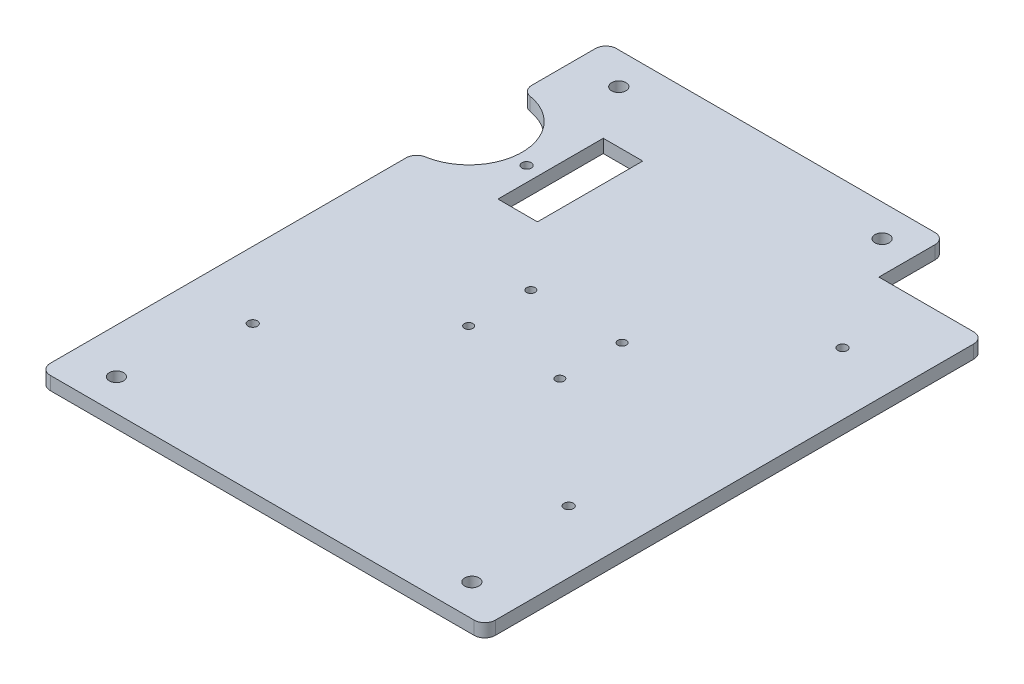
from build123d import *

# Parameters (mm, degrees)
SKETCH1_R           = 1.7272
BOSS_EXTRUDE1_DEPTH = 3.2004
SKETCH2_W           = 9.525
SKETCH2_H           = 25.4
CUT_EXTRUDE1_DEPTH  = 3.2004
SKETCH3_R           = 1.1303
CUT_EXTRUDE2_DEPTH  = 3.2004
FILLET1_R           = 2.54
SKETCH4_R           = 1.02489
CUT_EXTRUDE3_DEPTH  = 3.2004


with BuildPart() as part:
    # Sketch1 → Boss-Extrude1 (new body)
    with BuildSketch(Plane(origin=(0, 0, 0), x_dir=(1, 0, 0), z_dir=(0, 1, 0))):
        Polygon((0, 136.525), (0, 0), (107.315, 0), (107.315, 120.4468), (81.915, 120.4468), (81.915, 136.525), align=None)
        with Locations((10.795, 128.8415)):
            Circle(SKETCH1_R, mode=Mode.SUBTRACT)
        with Locations((96.52, 7.6835)):
            Circle(SKETCH1_R, mode=Mode.SUBTRACT)
        with Locations((10.795, 7.6835)):
            Circle(SKETCH1_R, mode=Mode.SUBTRACT)
        with Locations((74.295, 128.8415)):
            Circle(SKETCH1_R, mode=Mode.SUBTRACT)
    extrude(amount=BOSS_EXTRUDE1_DEPTH)

    # Sketch2 → Cut-Extrude1 (cut)
    with BuildSketch(Plane(origin=(0, 3.2004, 0), x_dir=(1, 0, 0), z_dir=(0, 1, 0))):
        with Locations((24.4475, 103.505)):
            Rectangle(SKETCH2_W, SKETCH2_H)
        with BuildLine():
            Line((0, 116.330365836), (0, 90.679634164))
            ThreePointArc((0, 90.679634164), (12.825365836, 103.505), (0, 116.330365836))
        make_face()
    extrude(amount=-CUT_EXTRUDE1_DEPTH, mode=Mode.SUBTRACT)

    # Sketch3 → Cut-Extrude2 (cut)
    with BuildSketch(Plane(origin=(0, 3.2004, 0), x_dir=(1, 0, 0), z_dir=(0, 1, 0))):
        with Locations((92.312807391, 101.2825)):
            Circle(SKETCH3_R)
        with Locations((92.312807391, 35.2425)):
            Circle(SKETCH3_R)
        with Locations((16.112807391, 35.2425)):
            Circle(SKETCH3_R)
        with Locations((16.112807391, 101.2825)):
            Circle(SKETCH3_R)
    extrude(amount=-CUT_EXTRUDE2_DEPTH, mode=Mode.SUBTRACT)

    # Fillet1
    fillet1_edges = [part.edges().sort_by_distance(p)[0] for p in [
        (0, 1.6002, 0),
        (0, 1.6002, -136.525),
        (81.915, 1.6002, -136.525),
        (107.315, 1.6002, -120.4468),
        (107.315, 1.6002, 0),
        (0, 1.6002, -90.679634164),
        (0, 1.6002, -116.330365836),
    ]]
    fillet(fillet1_edges, radius=FILLET1_R)

    # Sketch4 → Cut-Extrude3 (cut)
    with BuildSketch(Plane(origin=(0, 3.2004, 0), x_dir=(1, 0, 0), z_dir=(0, 1, 0))):
        with Locations((64.6575, 75.7625)):
            Circle(SKETCH4_R)
        with Locations((64.6575, 60.7625)):
            Circle(SKETCH4_R)
        with Locations((42.6575, 75.7625)):
            Circle(SKETCH4_R)
        with Locations((42.6575, 60.7625)):
            Circle(SKETCH4_R)
    extrude(amount=-CUT_EXTRUDE3_DEPTH, mode=Mode.SUBTRACT)


solid = part.part
